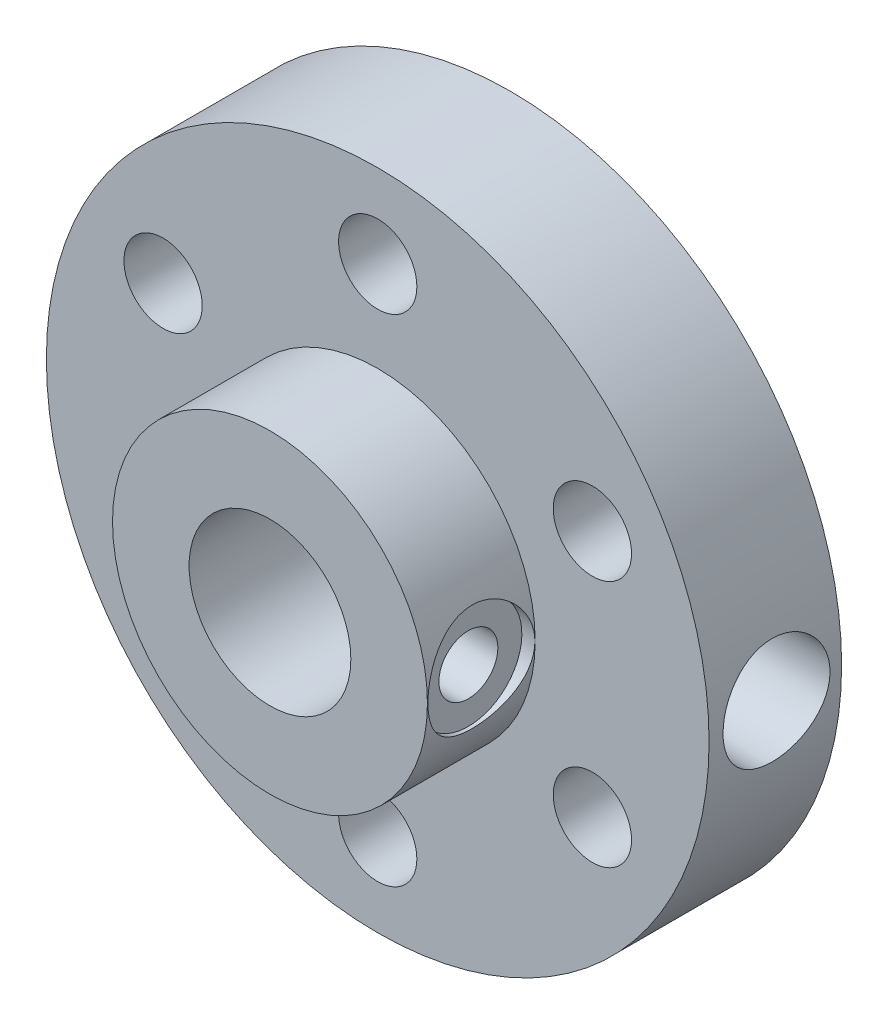
from build123d import *

# Parameters (mm, degrees)
SKETCH1_R                  = 12.7
BOSS_EXTRUDE1_DEPTH        = 5.08
SKETCH2_R                  = 6.035
BOSS_EXTRUDE2_DEPTH        = 4.13
CUT_EXTRUDE1_REACH         = 22.184
SKETCH3_R                  = 3.1
SKETCH16_R                 = 2.05
CUT_EXTRUDE2_DEPTH         = 0.5
F_4_40_TAPPED_HOLE3_REACH  = 26.055
F_4_40_TAPPED_HOLE3_BORE_R = 1.1303
SKETCH24_R                 = 2.05
CUT_EXTRUDE3_DEPTH         = 7.1
F_4_40_TAPPED_HOLE4_REACH  = 26.104
F_4_40_TAPPED_HOLE4_BORE_R = 1.1303
SKETCH29_R                 = 1.5
CUT_EXTRUDE4_DEPTH         = 10


with BuildPart() as part:
    # Sketch1 → Boss-Extrude1 (new body)
    with BuildSketch(Plane.XY):
        Circle(SKETCH1_R)
    extrude(amount=BOSS_EXTRUDE1_DEPTH)

    # Sketch2 → Boss-Extrude2 (add)
    with BuildSketch(Plane.XY.offset(5.08)):
        Circle(SKETCH2_R)
    extrude(amount=BOSS_EXTRUDE2_DEPTH)

    # Sketch3 → Cut-Extrude1 (cut, up to next)
    with BuildSketch(Plane.XY.offset(9.21), mode=Mode.PRIVATE) as cut_extrude1_sk1:
        Circle(SKETCH3_R)
    cut_extrude1_tool1 = extrude(cut_extrude1_sk1.sketch, amount=-CUT_EXTRUDE1_REACH, mode=Mode.PRIVATE) & part.part
    add(cut_extrude1_tool1.solids().sort_by_distance((0, 0, 9.21))[0], mode=Mode.SUBTRACT)

    # Sketch16 → Cut-Extrude2 (cut)
    with BuildSketch(Plane(origin=(6.035, 0, 9.21), x_dir=(0, 0, -1), z_dir=(1, 0, 0))):
        with Locations(Location((2.069027283, 0, 0), (0, 0, 90))):
            Circle(SKETCH16_R)
    extrude(amount=-CUT_EXTRUDE2_DEPTH, mode=Mode.SUBTRACT)

    # #4-40 Tapped Hole3 bore → #4-40 Tapped Hole3 (cut, up to next)
    with BuildSketch(Plane(origin=(5.535, 0, 0), x_dir=(0, 0, -1), z_dir=(1, 0, 0)), mode=Mode.PRIVATE) as f_4_40_tapped_hole3_sk1:
        with Locations((-7.140972717, 0)):
            Circle(F_4_40_TAPPED_HOLE3_BORE_R)
    f_4_40_tapped_hole3_tool1 = extrude(f_4_40_tapped_hole3_sk1.sketch, amount=-F_4_40_TAPPED_HOLE3_REACH, mode=Mode.PRIVATE) & part.part
    add(f_4_40_tapped_hole3_tool1.solids().sort_by_distance((5.535, 0, 7.140973))[0], mode=Mode.SUBTRACT)

    # Sketch24 → Cut-Extrude3 (cut)
    with BuildSketch(Plane(origin=(12.7, 0, 5.08), x_dir=(0, 0, -1), z_dir=(1, 0, 0))):
        with Locations(Location((2.585319139, 0, 0), (0, 0, 90))):
            Circle(SKETCH24_R)
    extrude(amount=-CUT_EXTRUDE3_DEPTH, mode=Mode.SUBTRACT)

    # #4-40 Tapped Hole4 bore → #4-40 Tapped Hole4 (cut, up to next)
    with BuildSketch(Plane(origin=(5.6, 0, 0), x_dir=(0, 0, -1), z_dir=(1, 0, 0)), mode=Mode.PRIVATE) as f_4_40_tapped_hole4_sk1:
        with Locations((-2.494680861, 0)):
            Circle(F_4_40_TAPPED_HOLE4_BORE_R)
    f_4_40_tapped_hole4_tool1 = extrude(f_4_40_tapped_hole4_sk1.sketch, amount=-F_4_40_TAPPED_HOLE4_REACH, mode=Mode.PRIVATE) & part.part
    add(f_4_40_tapped_hole4_tool1.solids().sort_by_distance((5.6, 0, 2.494681))[0], mode=Mode.SUBTRACT)

    # Sketch29 → Cut-Extrude4 (cut)
    with BuildSketch(Plane.XY.offset(5.08)):
        with Locations((0, 9.5)):
            Circle(SKETCH29_R)
        with Locations((8.227241336, 4.75)):
            Circle(SKETCH29_R)
        with Locations((8.227241336, -4.75)):
            Circle(SKETCH29_R)
        with Locations((0, -9.5)):
            Circle(SKETCH29_R)
        with Locations((-8.227241336, -4.75)):
            Circle(SKETCH29_R)
        with Locations((-8.227241336, 4.75)):
            Circle(SKETCH29_R)
    extrude(amount=-CUT_EXTRUDE4_DEPTH, mode=Mode.SUBTRACT)


solid = part.part
